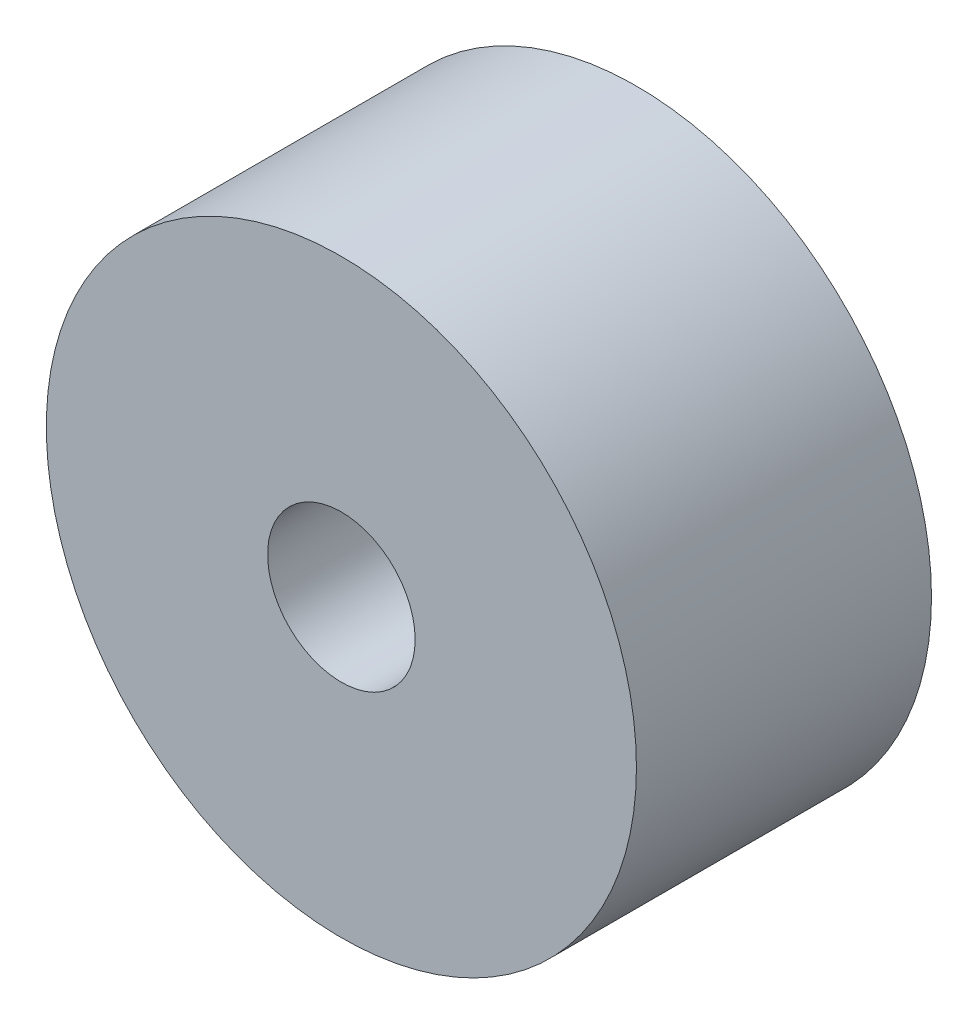
from build123d import *

# Parameters (mm, degrees)
SKETCH1_R           = 12.7
SKETCH1_R_2         = 3.175
BOSS_EXTRUDE1_DEPTH = 12.7


with BuildPart() as part:
    # Sketch1 → Boss-Extrude1 (new body)
    with BuildSketch(Plane.XY):
        Circle(SKETCH1_R)
        Circle(SKETCH1_R_2, mode=Mode.SUBTRACT)
    extrude(amount=BOSS_EXTRUDE1_DEPTH)


solid = part.part
